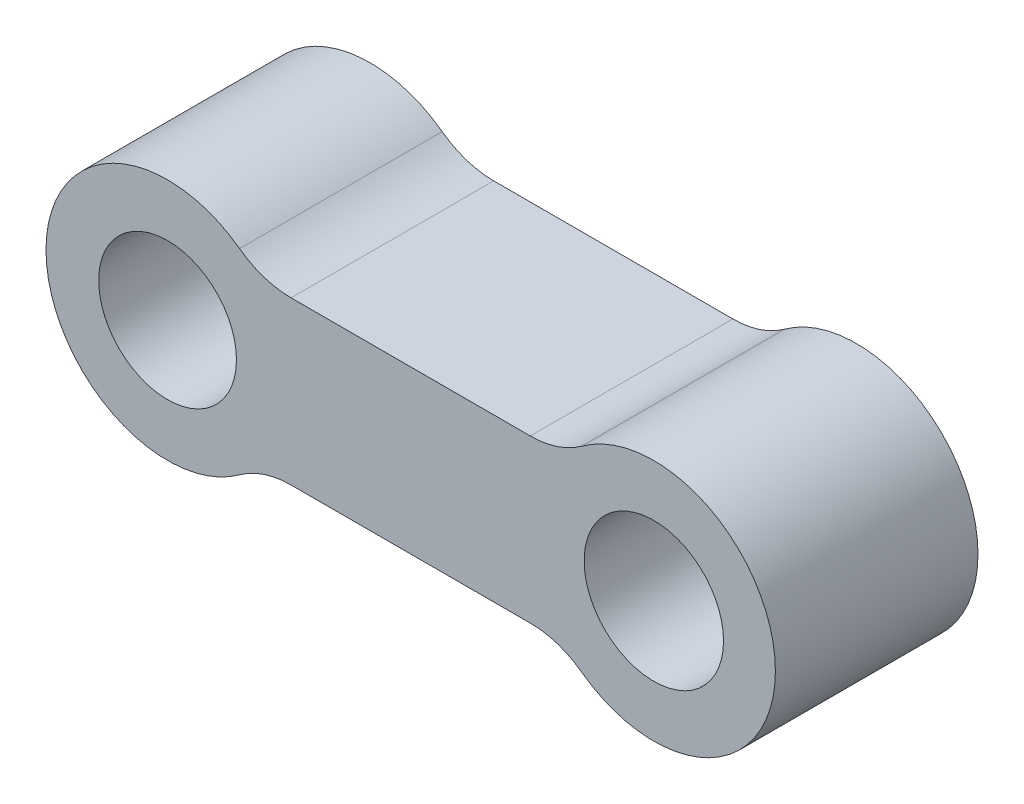
from build123d import *

# Parameters (mm, degrees)
CROQUIS1_R              = 4.25
CROQUIS1_R_2            = 4.3
SALIENTE_EXTRUIR1_DEPTH = 12.5


with BuildPart() as part:
    # Croquis1 → Saliente-Extruir1 (new body)
    with BuildSketch(Plane.XY):
        with BuildLine():
            Line((-7.377684836, -5), (7.377684836, -5))
            ThreePointArc((7.377684836, -5), (9.051224581, -5.267438742), (10.558069892, -6.04311649))
            ThreePointArc((10.558069892, -6.04311649), (22.5, 0), (10.558069892, 6.04311649))
            ThreePointArc((10.558069892, 6.04311649), (9.051224581, 5.267438742), (7.377684836, 5))
            Line((7.377684836, 5), (-7.377684836, 5))
            ThreePointArc((-7.377684836, 5), (-9.051224581, 5.267438742), (-10.558069892, 6.04311649))
            ThreePointArc((-10.558069892, 6.04311649), (-22.5, 0), (-10.558069892, -6.04311649))
            ThreePointArc((-10.558069892, -6.04311649), (-9.051224581, -5.267438742), (-7.377684836, -5))
        make_face()
        with Locations((-15, 0)):
            Circle(CROQUIS1_R, mode=Mode.SUBTRACT)
        with Locations((15, 0)):
            Circle(CROQUIS1_R_2, mode=Mode.SUBTRACT)
    extrude(amount=SALIENTE_EXTRUIR1_DEPTH)


solid = part.part
